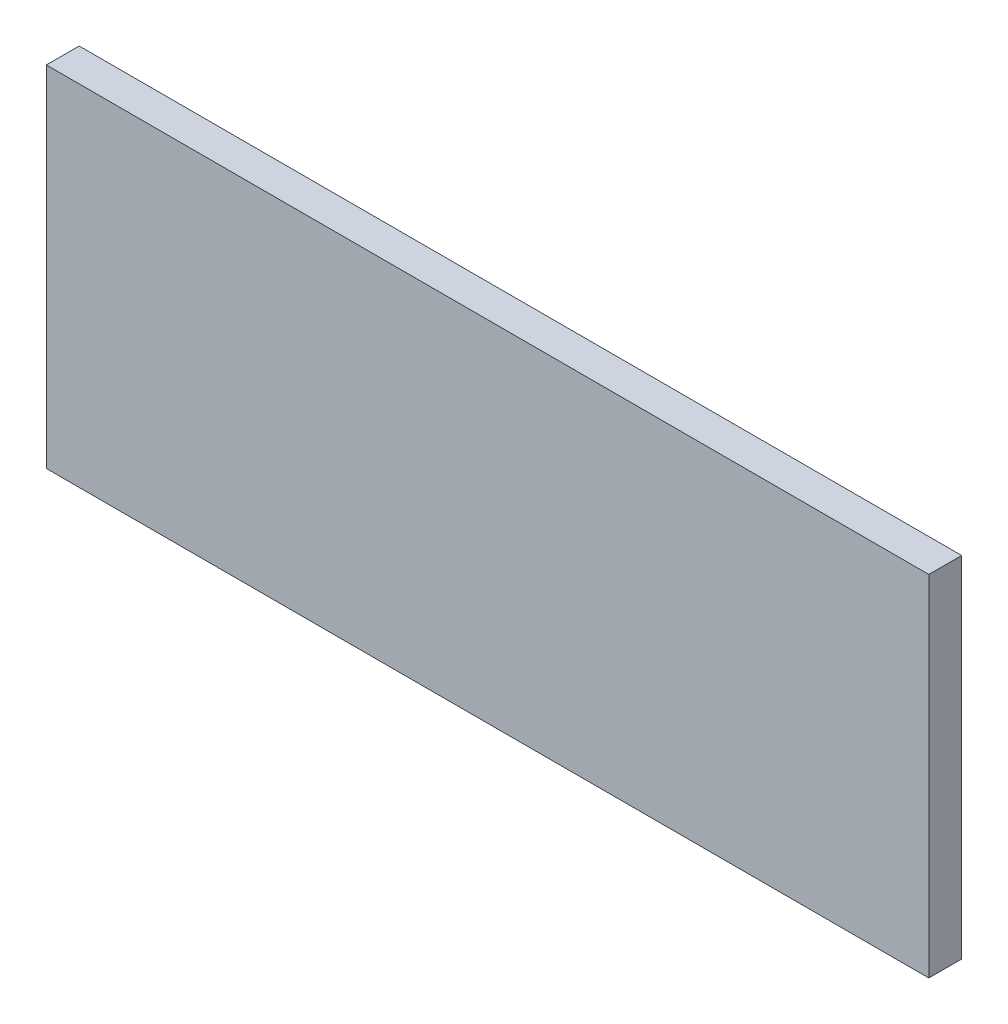
from build123d import *

# Parameters (mm, degrees)
SKETCH1_W           = 26.870568318
SKETCH1_H           = 10.641935924
BOSS_EXTRUDE1_DEPTH = 1


with BuildPart() as part:
    # Sketch1 → Boss-Extrude1 (new body)
    with BuildSketch(Plane.XY.offset(14.927750355)):
        with Locations((25.484048031, 53.718310828)):
            Rectangle(SKETCH1_W, SKETCH1_H)
    extrude(amount=BOSS_EXTRUDE1_DEPTH)


solid = part.part
